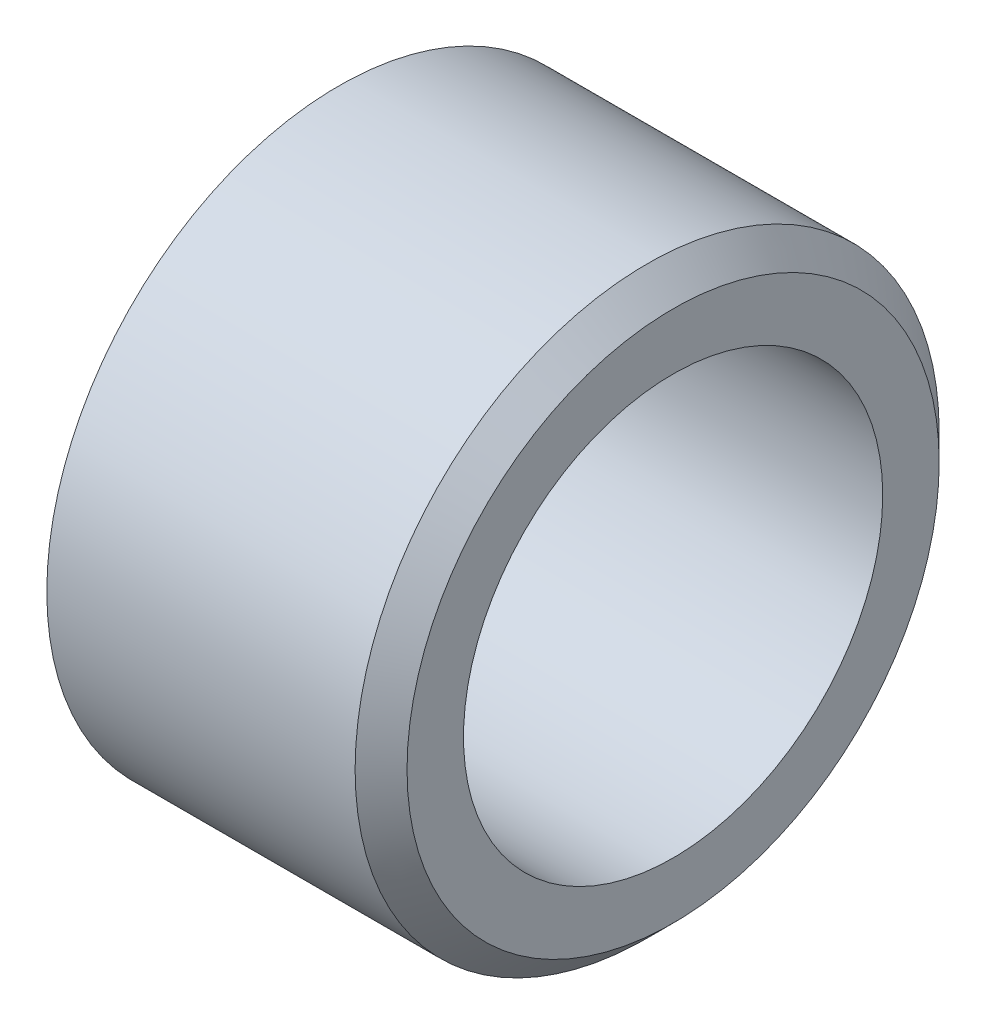
from build123d import *

# Parameters (mm, degrees)
P_0_323_DIAMETER_HOLE1_D = 8.2042


with BuildPart() as part:
    # Sketch1 → Revolve1 (revolve)
    with BuildSketch(Plane(origin=(0, 219.633662308, 0), x_dir=(1, 0, 0), z_dir=(0, 1, 0))):
        Polygon((-4, -542.126277454), (-4, -536.919277454), (-4.508, -536.411277454), (-10.541, -536.411277454), (-10.541, -542.126277454), align=None)
    revolve(axis=Axis((-10.541, 219.633662308, 542.126277454), (1, 0, 0)))

    # P _0.323_ Diameter Hole1 (through all)
    with Locations(Plane(origin=(-4, 0, 0), x_dir=(0, 0, -1), z_dir=(1, 0, 0))):
        with Locations((-542.126277454, 219.633662308)):
            Hole(P_0_323_DIAMETER_HOLE1_D / 2)


solid = part.part
